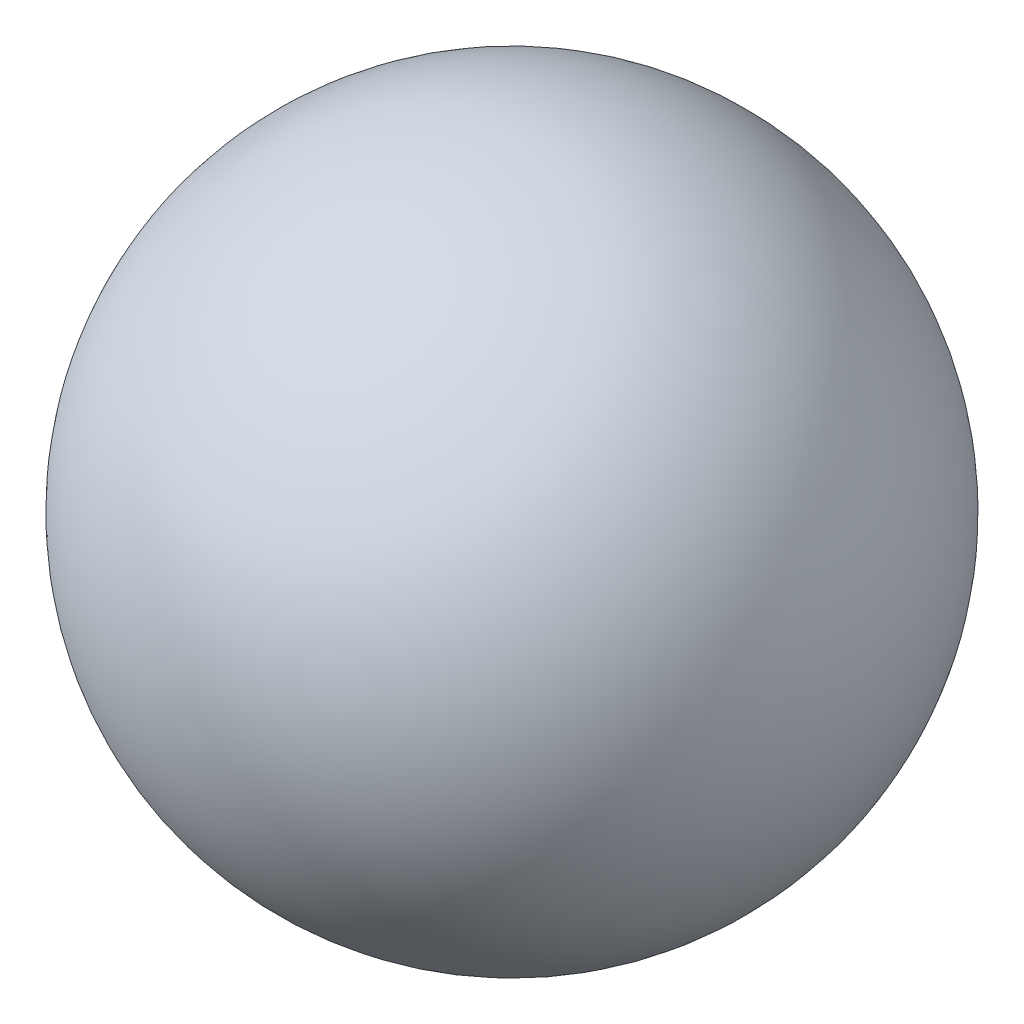
from build123d import *


with BuildPart() as part:
    # Sketch1 → Revolve1 (revolve)
    with BuildSketch(Plane.XY):
        with BuildLine():
            Line((-12, 0), (12, 0))
            ThreePointArc((12, 0), (0, 12), (-12, 0))
        make_face()
    revolve(axis=Axis((-14.301461938, 0, 0), (1, 0, 0)))


solid = part.part
